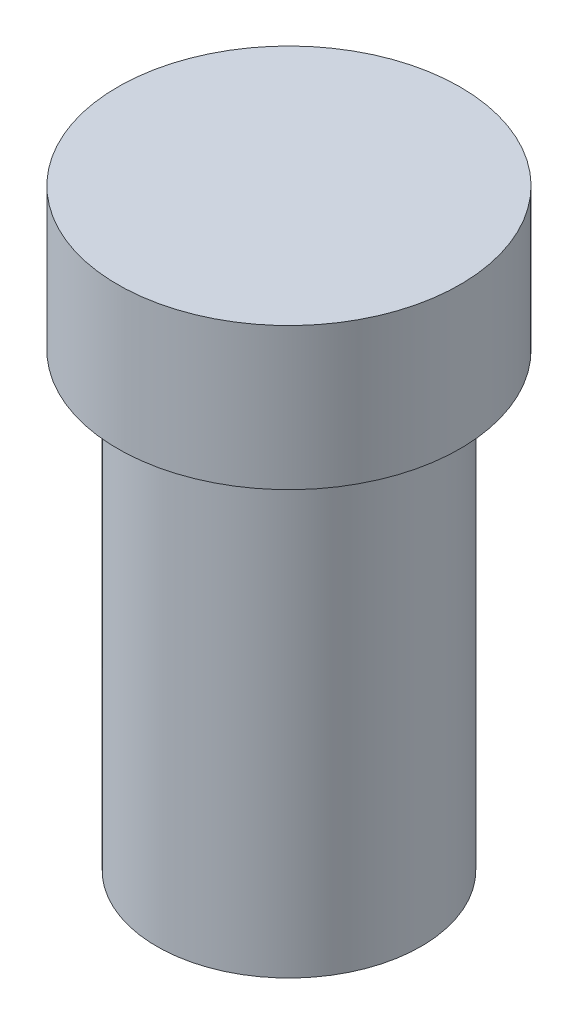
from build123d import *

# Parameters (mm, degrees)
FILLET1_R = 4


with BuildPart() as part:
    # Sketch1 → Revolve1 (revolve)
    with BuildSketch(Plane.XY, mode=Mode.PRIVATE) as revolve1_sk:
        Polygon((0, 0), (22, 0), (22, 75), (28.5, 75), (28.5, 98.659305994), (0, 98.659305994), align=None)
    revolve(revolve1_sk.sketch.rotate(Axis((0, 0, 0), (0, 1, 0)), 90), axis=Axis((0, 0, 0), (0, 1, 0)))  # turned: the seam where the file's is

    # Fillet1
    fillet1_edges = [part.edges().sort_by_distance(p)[0] for p in [
        (0, 75, 22),
    ]]
    fillet(fillet1_edges, radius=FILLET1_R)


solid = part.part
